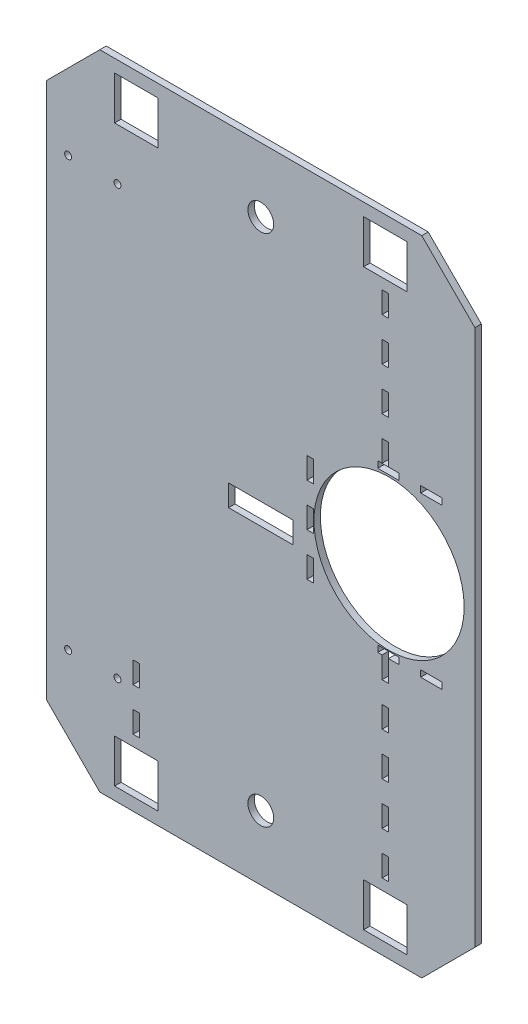
from build123d import *

# Parameters (mm, degrees)
BASE_DEPTH                      = 3
ESQUISSE3_W                     = 20.2
ESQUISSE3_H                     = 20.2
ENL_V_MAT_EXTRU_1_DEPTH         = 4
R_P_TITION_LIN_AIRE1_COUNT      = 2
R_P_TITION_LIN_AIRE1_PITCH      = 267.5
R_P_TITION_LIN_AIRE1_COUNT_DIR2 = 2
R_P_TITION_LIN_AIRE1_PITCH_DIR2 = 116
ESQUISSE4_R                     = 35
ENL_V_MAT_EXTRU_2_DEPTH         = 4
ESQUISSE5_R                     = 6
ESQUISSE5_W                     = 30
ESQUISSE5_H                     = 10
ENL_V_MAT_EXTRU_3_DEPTH         = 4
ESQUISSE6_R                     = 1.625
ENL_V_MAT_EXTRU_4_DEPTH         = 4
SKETCH1_W                       = 3
SKETCH1_H                       = 10
CUT_EXTRUDE1_DEPTH              = 4
LPATTERN1_COUNT                 = 4
LPATTERN1_PITCH                 = 20
SKETCH2_W                       = 3
SKETCH2_H                       = 10
CUT_EXTRUDE2_DEPTH              = 4
LPATTERN2_COUNT                 = 5
LPATTERN2_PITCH                 = 20
SKETCH4_W                       = 3
SKETCH4_H                       = 10
CUT_EXTRUDE3_DEPTH              = 4
LPATTERN3_COUNT                 = 2
LPATTERN3_PITCH                 = 20
ESQUISSE7_W                     = 10
ESQUISSE7_H                     = 3
ENL_V_MAT_EXTRU_5_DEPTH         = 3
ESQUISSE8_W                     = 3
ESQUISSE8_H                     = 10
ENL_V_MAT_EXTRU_6_DEPTH         = 3


with BuildPart() as part:
    # Esquisse1 → Base (new body)
    with BuildSketch(Plane.XY):
        Polygon((24.748737342, 24.748737342), (0, 0), (-150, 0), (-174.748737342, 24.748737342), (-174.748737342, 274.748737342), (-150, 299.497474683), (0, 299.497474683), (24.748737342, 274.748737342), align=None)
    extrude(amount=BASE_DEPTH)

    # Esquisse3 → Enlèv. mat.-Extru.1 (cut, through all)
    with BuildSketch(Plane.XY.offset(3)):
        with Locations((-132.998737342, 16)):
            Rectangle(ESQUISSE3_W, ESQUISSE3_H)
    enl_v_mat_extru_1 = extrude(amount=-ENL_V_MAT_EXTRU_1_DEPTH, mode=Mode.SUBTRACT)

    # Répétition linéaire1: Enl_v. mat.-Extru.1 2 × 2
    with Locations(*[(j * R_P_TITION_LIN_AIRE1_PITCH_DIR2, i * R_P_TITION_LIN_AIRE1_PITCH, 0) for i in range(R_P_TITION_LIN_AIRE1_COUNT) for j in range(R_P_TITION_LIN_AIRE1_COUNT_DIR2) if (i, j) != (0, 0)]):
        add(enl_v_mat_extru_1, mode=Mode.SUBTRACT)

    # Esquisse4 → Enlèv. mat.-Extru.2 (cut, through all)
    with BuildSketch(Plane.XY.offset(3)):
        with Locations((-15.251262658, 159.497474683)):
            Circle(ESQUISSE4_R)
    extrude(amount=-ENL_V_MAT_EXTRU_2_DEPTH, mode=Mode.SUBTRACT)

    # Esquisse5 → Enlèv. mat.-Extru.3 (cut, through all)
    with BuildSketch(Plane.XY.offset(3)):
        with Locations((-75, 30)):
            Circle(ESQUISSE5_R)
        with Locations((-75, 269.497474683)):
            Circle(ESQUISSE5_R)
        with Locations((-75, 149.748737342)):
            Rectangle(ESQUISSE5_W, ESQUISSE5_H)
    extrude(amount=-ENL_V_MAT_EXTRU_3_DEPTH, mode=Mode.SUBTRACT)

    # Esquisse6 → Enlèv. mat.-Extru.4 (cut, through all)
    with BuildSketch(Plane.XY.offset(3)):
        with Locations((-164.748737342, 249.497474683)):
            Circle(ESQUISSE6_R)
        with Locations((-141.748737342, 249.497474683)):
            Circle(ESQUISSE6_R)
        with Locations((-164.748737342, 50)):
            Circle(ESQUISSE6_R)
        with Locations((-141.748737342, 50)):
            Circle(ESQUISSE6_R)
    extrude(amount=-ENL_V_MAT_EXTRU_4_DEPTH, mode=Mode.SUBTRACT)

    # Sketch1 → Cut-Extrude1 (cut, through all)
    with BuildSketch(Plane.XY.offset(3)):
        with Locations((-16.998737342, 263.4)):
            Rectangle(SKETCH1_W, SKETCH1_H)
    cut_extrude1 = extrude(amount=-CUT_EXTRUDE1_DEPTH, mode=Mode.SUBTRACT)

    # LPattern1: Cut-Extrude1 ×4
    with Locations(*[(0, -i * LPATTERN1_PITCH, 0) for i in range(1, LPATTERN1_COUNT)]):
        add(cut_extrude1, mode=Mode.SUBTRACT)

    # Sketch2 → Cut-Extrude2 (cut, through all)
    with BuildSketch(Plane.XY.offset(3)):
        with Locations((-16.998737342, 36.1)):
            Rectangle(SKETCH2_W, SKETCH2_H)
    cut_extrude2 = extrude(amount=-CUT_EXTRUDE2_DEPTH, mode=Mode.SUBTRACT)

    # LPattern2: Cut-Extrude2 ×5
    with Locations(*[(0, i * LPATTERN2_PITCH, 0) for i in range(1, LPATTERN2_COUNT)]):
        add(cut_extrude2, mode=Mode.SUBTRACT)

    # Sketch4 → Cut-Extrude3 (cut, through all)
    with BuildSketch(Plane.XY.offset(3)):
        with Locations((-132.998737342, 36.1)):
            Rectangle(SKETCH4_W, SKETCH4_H)
    cut_extrude3 = extrude(amount=-CUT_EXTRUDE3_DEPTH, mode=Mode.SUBTRACT)

    # LPattern3: Cut-Extrude3 ×2
    with Locations(*[(0, i * LPATTERN3_PITCH, 0) for i in range(1, LPATTERN3_COUNT)]):
        add(cut_extrude3, mode=Mode.SUBTRACT)

    # Esquisse7 → Enlèv. mat.-Extru.5 (cut)
    with BuildSketch(Plane.XY.offset(3)):
        with Locations((4.498737342, 122.6)):
            Rectangle(ESQUISSE7_W, ESQUISSE7_H)
        with Locations((-15.501262658, 196.897474683)):
            Rectangle(ESQUISSE7_W, ESQUISSE7_H)
        with Locations((4.498737342, 196.897474683)):
            Rectangle(ESQUISSE7_W, ESQUISSE7_H)
        with Locations((-15.501262658, 122.6)):
            Rectangle(ESQUISSE7_W, ESQUISSE7_H)
    extrude(amount=-ENL_V_MAT_EXTRU_5_DEPTH, mode=Mode.SUBTRACT)

    # Esquisse8 → Enlèv. mat.-Extru.6 (cut)
    with BuildSketch(Plane.XY.offset(3)):
        with Locations((-52.001262658, 159.1)):
            Rectangle(ESQUISSE8_W, ESQUISSE8_H)
        with Locations((-52.001262658, 139.1)):
            Rectangle(ESQUISSE8_W, ESQUISSE8_H)
        with Locations((-52.001262658, 179.1)):
            Rectangle(ESQUISSE8_W, ESQUISSE8_H)
    extrude(amount=-ENL_V_MAT_EXTRU_6_DEPTH, mode=Mode.SUBTRACT)


solid = part.part
